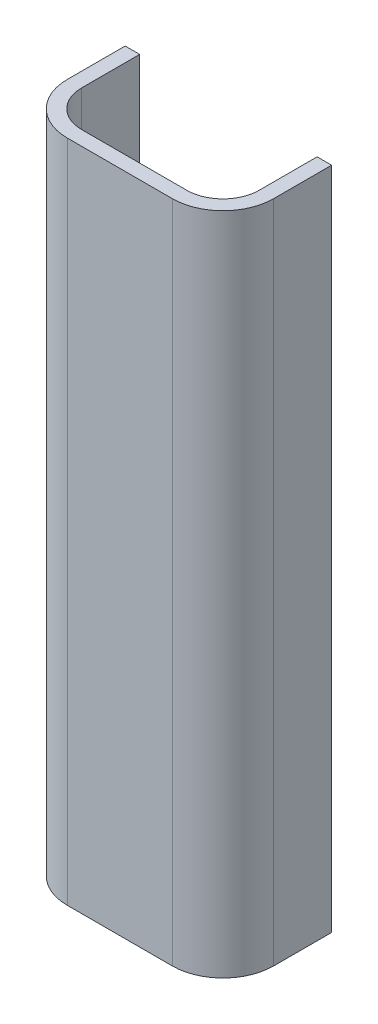
from build123d import *
from build123d.topology import SkipClean

# Parameters (mm, degrees)
SKETCH1_W           = 57
SKETCH1_H           = 183.5
SKETCH1_W_2         = 49
SKETCH1_H_2         = 175.5
BOSS_EXTRUDE1_DEPTH = 30
BOSS_EXTRUDE2_DEPTH = 175.5
FILLET1_R           = 14
CUT_EXTRUDE1_DEPTH  = 179.5


with BuildPart() as part:
    # Sketch1 → Boss-Extrude1 (new body)
    with BuildSketch(Plane.XY):
        with Locations((0, 18.25)):
            Rectangle(SKETCH1_W, SKETCH1_H)
        with Locations((0, 18.25)):
            Rectangle(SKETCH1_W_2, SKETCH1_H_2, mode=Mode.SUBTRACT)
    extrude(amount=BOSS_EXTRUDE1_DEPTH)

    # Sketch2 → Boss-Extrude2 (add)
    with BuildSketch(Plane(origin=(0, -69.5, 0), x_dir=(1, 0, 0), z_dir=(0, 1, 0))):
        with BuildLine():
            Line((14.5, -26), (24.5, -26))
            Line((24.5, -26), (24.5, -16))
            ThreePointArc((24.5, -16), (21.571067812, -23.071067812), (14.5, -26))
        make_face()
        Polygon((-24.5, -30), (24.5, -30), (24.5, -26), (14.5, -26), (-14.5, -26), (-24.5, -26), align=None)
        with BuildLine():
            Line((-24.5, -16), (-24.5, -26))
            Line((-24.5, -26), (-14.5, -26))
            ThreePointArc((-14.5, -26), (-21.571067812, -23.071067812), (-24.5, -16))
        make_face()
    extrude(amount=BOSS_EXTRUDE2_DEPTH)

    # Fillet1
    fillet1_edges = [part.edges().sort_by_distance(p)[0] for p in [
        (-28.5, 18.25, 30),
        (28.5, 18.25, 30),
    ]]
    fillet(fillet1_edges, radius=FILLET1_R)

    # Sketch2_4 → Cut-Extrude1 (cut)
    with SkipClean():  # the faces are left unmerged after this step: merging them gives an invalid solid
        with BuildSketch(Plane(origin=(0, -69.5, 0), x_dir=(1, 0, 0), z_dir=(0, 1, 0))):
            with BuildLine():
                Line((-14.5, -26), (14.5, -26))
                ThreePointArc((14.5, -26), (21.571067812, -23.071067812), (24.5, -16))
                Line((24.5, -16), (24.5, 0))
                Line((24.5, 0), (-24.5, 0))
                Line((-24.5, 0), (-24.5, -16))
                ThreePointArc((-24.5, -16), (-21.571067812, -23.071067812), (-14.5, -26))
            make_face()
        extrude(amount=CUT_EXTRUDE1_DEPTH, mode=Mode.SUBTRACT)


solid = part.part
